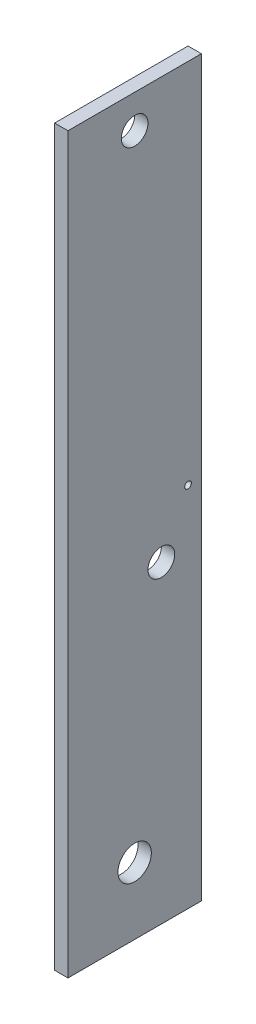
from build123d import *

# Parameters (mm, degrees)
SKETCH1_W           = 20
SKETCH1_H           = 110
BOSS_EXTRUDE1_DEPTH = 2
SKETCH2_R           = 2.5
SKETCH2_R_2         = 2
SKETCH2_R_3         = 0.5
CUT_EXTRUDE1_DEPTH  = 2


with BuildPart() as part:
    # Sketch1 → Boss-Extrude1 (new body)
    with BuildSketch(Plane(origin=(0, 0, 0), x_dir=(0, 0, -1), z_dir=(1, 0, 0))):
        with Locations((10, 55)):
            Rectangle(SKETCH1_W, SKETCH1_H)
    extrude(amount=BOSS_EXTRUDE1_DEPTH)

    # Sketch2 → Cut-Extrude1 (cut)
    with BuildSketch(Plane(origin=(2, 0, 0), x_dir=(0, 0, -1), z_dir=(1, 0, 0))):
        with Locations((10, 10)):
            Circle(SKETCH2_R)
        with Locations((10, 105)):
            Circle(SKETCH2_R_2)
        with Locations((14, 47)):
            Circle(SKETCH2_R_2)
        with Locations((18, 55)):
            Circle(SKETCH2_R_3)
    extrude(amount=-CUT_EXTRUDE1_DEPTH, mode=Mode.SUBTRACT)


solid = part.part
